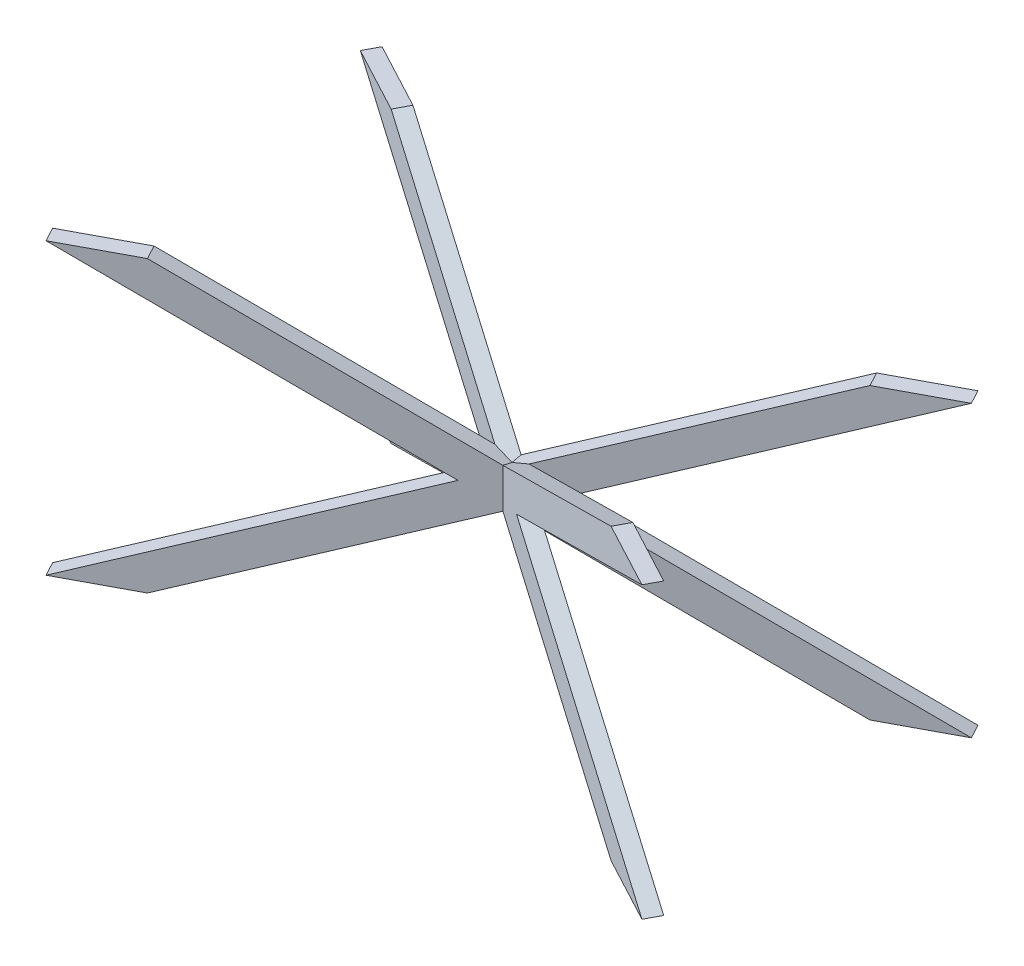
from build123d import *

# Parameters (mm, degrees)
DODANIE_WYCI_GNI_CIE1_DEPTH      = 20
DODANIE_WYCI_GNI_CIE1_DEPTH_BACK = 20
DODANIE_WYCI_GNI_CIE2_DEPTH      = 20
DODANIE_WYCI_GNI_CIE2_DEPTH_BACK = 20
DODANIE_WYCI_GNI_CIE3_DEPTH      = 20
DODANIE_WYCI_GNI_CIE3_DEPTH_BACK = 20
DODANIE_WYCI_GNI_CIE4_DEPTH      = 20
DODANIE_WYCI_GNI_CIE4_DEPTH_BACK = 20


with BuildPart() as part:
    # Szkic4 → Dodanie-wyci_gni_cie1 (new body, two sides)
    with BuildSketch(Plane(origin=(179.528354859, 0, -336.615665361), x_dir=(0.882352941, 0, 0.470588235), z_dir=(-0.470588235, 0, 0.882352941))) as dodanie_wyci_gni_cie1_sk:
        Polygon((-984.691711107, 436.10738255), (529.057535882, -283.89261745), (715.308288893, -283.89261745), (-798.440958097, 436.10738255), align=None)
    extrude(amount=DODANIE_WYCI_GNI_CIE1_DEPTH)
    extrude(dodanie_wyci_gni_cie1_sk.sketch, amount=-DODANIE_WYCI_GNI_CIE1_DEPTH_BACK)

    # Szkic5 → Dodanie-wyci_gni_cie2 (add, two sides)
    with BuildSketch(Plane(origin=(179.528354859, 0, -336.615665361), x_dir=(0.882352941, 0, 0.470588235), z_dir=(-0.470588235, 0, 0.882352941))) as dodanie_wyci_gni_cie2_sk:
        Polygon((-984.691711107, -283.89261745), (529.057535882, 436.10738255), (715.308288893, 436.10738255), (-798.440958097, -283.89261745), align=None)
    extrude(amount=DODANIE_WYCI_GNI_CIE2_DEPTH)
    extrude(dodanie_wyci_gni_cie2_sk.sketch, amount=-DODANIE_WYCI_GNI_CIE2_DEPTH_BACK)

    # Szkic6 → Dodanie-wyci_gni_cie3 (add, two sides)
    with BuildSketch(Plane(origin=(-152.651575936, 0, -286.221704881), x_dir=(0.882352941, 0, -0.470588235), z_dir=(0.470588235, 0, 0.882352941))) as dodanie_wyci_gni_cie3_sk:
        Polygon((1091.778877128, -283.89261745), (-421.970369861, 436.10738255), (-608.221122872, 436.10738255), (905.528124117, -283.89261745), align=None)
    extrude(amount=DODANIE_WYCI_GNI_CIE3_DEPTH)
    extrude(dodanie_wyci_gni_cie3_sk.sketch, amount=-DODANIE_WYCI_GNI_CIE3_DEPTH_BACK)

    # Szkic7 → Dodanie-wyci_gni_cie4 (add, two sides)
    with BuildSketch(Plane(origin=(-152.651575936, 0, -286.221704881), x_dir=(0.882352941, 0, -0.470588235), z_dir=(0.470588235, 0, 0.882352941))) as dodanie_wyci_gni_cie4_sk:
        Polygon((-421.970369861, -283.89261745), (1091.778877128, 436.10738255), (905.528124117, 436.10738255), (-608.221122872, -283.89261745), align=None)
    extrude(amount=DODANIE_WYCI_GNI_CIE4_DEPTH)
    extrude(dodanie_wyci_gni_cie4_sk.sketch, amount=-DODANIE_WYCI_GNI_CIE4_DEPTH_BACK)


solid = part.part
